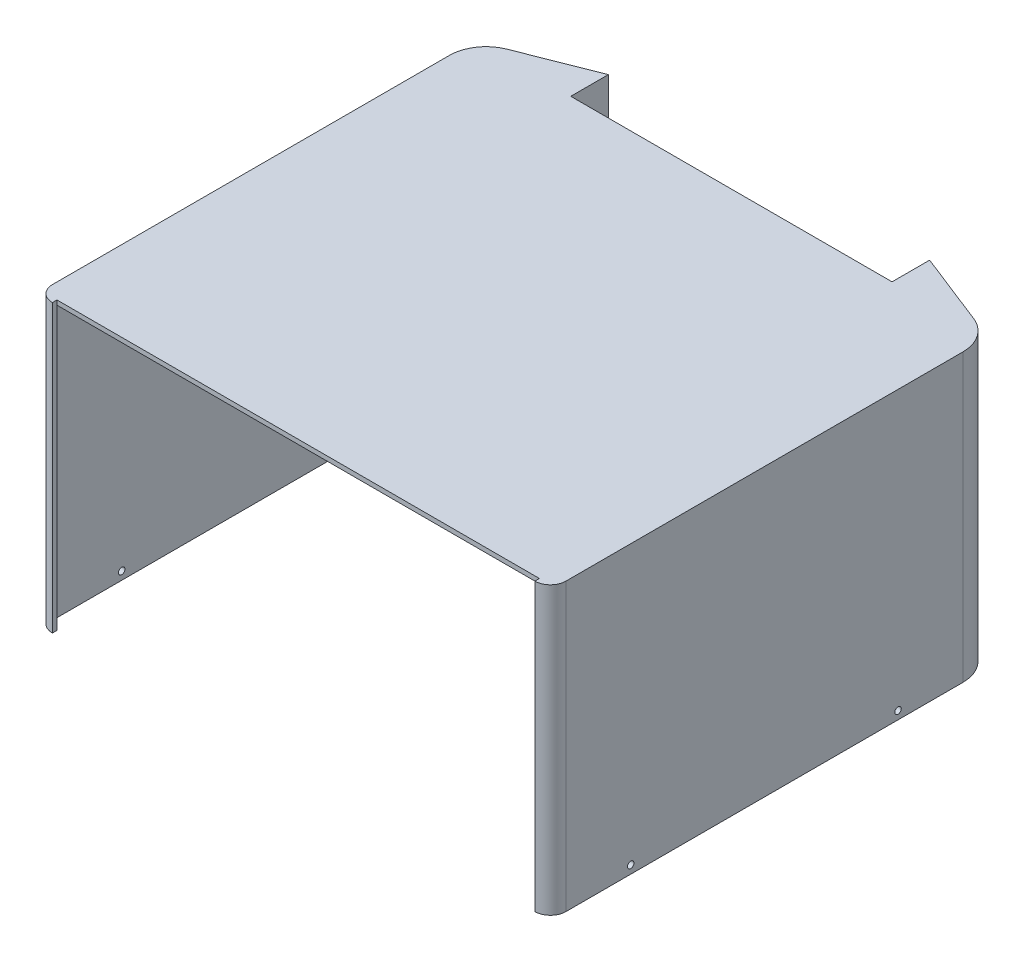
from build123d import *

# Parameters (mm, degrees)
BOSS_EXTRUDE2_DEPTH = 82
BOSS_EXTRUDE3_DEPTH = 1.5
SKETCH4_W           = 149
SKETCH4_H           = 82
CUT_EXTRUDE2_DEPTH  = 1.5
SKETCH5_W           = 99.231457505
SKETCH5_H           = 0.2
CUT_EXTRUDE3_DEPTH  = 18
SKETCH6_R           = 1
CUT_EXTRUDE4_DEPTH  = 243
CUT_EXTRUDE5_DEPTH  = 16.4
BOSS_EXTRUDE4_DEPTH = 5
BOSS_EXTRUDE6_DEPTH = 1.4
SKETCH10_W          = 99.231457505
SKETCH10_H          = 5.34
SKETCH10_H_2        = 1.4
BOSS_EXTRUDE7_DEPTH = 1.4


with BuildPart() as part:
    # Sketch1 → Boss-Extrude2 (new body)
    with BuildSketch(Plane(origin=(0, 0, 0), x_dir=(1, 0, 0), z_dir=(0, 1, 0))):
        with BuildLine():
            Line((-0.443676805, -72.739461341), (-0.443676805, -74.139461341))
            Line((-0.443676805, -74.139461341), (74.056323195, -74.139461341))
            ThreePointArc((74.056323195, -74.139461341), (77.450435745, -72.733573891), (78.856323195, -69.339461341))
            Line((78.856323195, -69.339461341), (78.856323195, -3.839461341))
            Line((78.856323195, -3.839461341), (78.856323195, 53.213038835))
            ThreePointArc((78.856323195, 53.213038835), (76.87852757, 59.630364191), (71.631399559, 63.820995158))
            Line((71.631399559, 63.820995158), (49.172051948, 72.660538659))
            Line((49.172051948, 72.660538659), (49.172051948, 71.156007577))
            Line((49.172051948, 71.156007577), (49.172051948, 59.660538659))
            Line((49.172051948, 59.660538659), (50.572051948, 59.660538659))
            Line((50.572051948, 59.660538659), (50.572051948, 70.604995984))
            Line((50.572051948, 70.604995984), (71.118670883, 62.51826368))
            ThreePointArc((71.118670883, 62.51826368), (75.721414752, 58.842271604), (77.456323195, 53.213038835))
            Line((77.456323195, 53.213038835), (77.456323195, -3.839461341))
            Line((77.456323195, -3.839461341), (77.456323195, -69.339461341))
            ThreePointArc((77.456323195, -69.339461341), (76.460486251, -71.743624398), (74.056323195, -72.739461341))
            Line((74.056323195, -72.739461341), (-0.443676805, -72.739461341))
        make_face()
        with BuildLine():
            Line((-74.943676805, -74.139461341), (-0.443676805, -74.139461341))
            Line((-0.443676805, -74.139461341), (-0.443676805, -72.739461341))
            Line((-0.443676805, -72.739461341), (-74.943676805, -72.739461341))
            ThreePointArc((-74.943676805, -72.739461341), (-77.347839861, -71.743624398), (-78.343676805, -69.339461341))
            Line((-78.343676805, -69.339461341), (-78.343676805, -3.839461341))
            Line((-78.343676805, -3.839461341), (-78.343676805, 53.213038835))
            ThreePointArc((-78.343676805, 53.213038835), (-76.608768361, 58.842271604), (-72.006024493, 62.51826368))
            Line((-72.006024493, 62.51826368), (-51.459405557, 70.604995984))
            Line((-51.459405557, 70.604995984), (-51.459405557, 59.660538659))
            Line((-51.459405557, 59.660538659), (-50.059405557, 59.660538659))
            Line((-50.059405557, 59.660538659), (-50.059405557, 71.156007577))
            Line((-50.059405557, 71.156007577), (-50.059405557, 72.660538659))
            Line((-50.059405557, 72.660538659), (-72.518753169, 63.820995158))
            ThreePointArc((-72.518753169, 63.820995158), (-77.765881179, 59.630364191), (-79.743676805, 53.213038835))
            Line((-79.743676805, 53.213038835), (-79.743676805, -3.839461341))
            Line((-79.743676805, -3.839461341), (-79.743676805, -69.339461341))
            ThreePointArc((-79.743676805, -69.339461341), (-78.337789355, -72.733573891), (-74.943676805, -74.139461341))
        make_face()
    extrude(amount=BOSS_EXTRUDE2_DEPTH)

    # Sketch3 → Boss-Extrude3 (add)
    with BuildSketch(Plane(origin=(0, 82, 0), x_dir=(1, 0, 0), z_dir=(0, 1, 0))):
        with BuildLine():
            Line((-50.059405557, 59.660538659), (49.172051948, 59.660538659))
            Line((49.172051948, 59.660538659), (50.572051948, 59.660538659))
            Line((50.572051948, 59.660538659), (50.572051948, 70.604995984))
            Line((50.572051948, 70.604995984), (71.118670883, 62.51826368))
            ThreePointArc((71.118670883, 62.51826368), (75.721414752, 58.842271604), (77.456323195, 53.213038835))
            Line((77.456323195, 53.213038835), (77.456323195, -69.339461341))
            ThreePointArc((77.456323195, -69.339461341), (76.460486251, -71.743624398), (74.056323195, -72.739461341))
            Line((74.056323195, -72.739461341), (-74.943676805, -72.739461341))
            ThreePointArc((-74.943676805, -72.739461341), (-77.347839861, -71.743624398), (-78.343676805, -69.339461341))
            Line((-78.343676805, -69.339461341), (-78.343676805, 53.213038835))
            ThreePointArc((-78.343676805, 53.213038835), (-76.608768361, 58.842271604), (-72.006024493, 62.51826368))
            Line((-72.006024493, 62.51826368), (-51.459405557, 70.604995984))
            Line((-51.459405557, 70.604995984), (-51.459405557, 59.660538659))
            Line((-51.459405557, 59.660538659), (-50.059405557, 59.660538659))
        make_face()
    extrude(amount=-BOSS_EXTRUDE3_DEPTH)

    # Sketch4 → Cut-Extrude2 (cut)
    with BuildSketch(Plane.XY.offset(74.139461341)):
        with Locations((-0.443676805, 41)):
            Rectangle(SKETCH4_W, SKETCH4_H)
    extrude(amount=-CUT_EXTRUDE2_DEPTH, mode=Mode.SUBTRACT)

    # Sketch5 → Cut-Extrude3 (cut)
    with BuildSketch(Plane(origin=(0, 82, 0), x_dir=(1, 0, 0), z_dir=(0, 1, 0))):
        with Locations((-0.443676805, 59.560538659)):
            Rectangle(SKETCH5_W, SKETCH5_H)
    extrude(amount=-CUT_EXTRUDE3_DEPTH, mode=Mode.SUBTRACT)

    # Sketch6 → Cut-Extrude4 (cut)
    with BuildSketch(Plane.ZY.offset(79.743676805)):
        with Locations((-33.213038835, 2.5)):
            Circle(SKETCH6_R)
        with Locations((49.339461341, 2.5)):
            Circle(SKETCH6_R)
    extrude(amount=-CUT_EXTRUDE4_DEPTH, mode=Mode.SUBTRACT)

    # Sketch7 → Cut-Extrude5 (cut)
    with BuildSketch(Plane.XZ.offset(-80.5)):
        with BuildLine():
            Line((-50.059405557, -59.460538659), (49.172051948, -59.460538659))
            Line((49.172051948, -59.460538659), (49.172051948, -59.660538659))
            Line((49.172051948, -59.660538659), (50.572051948, -59.660538659))
            Line((50.572051948, -59.660538659), (50.572051948, -70.604995984))
            Line((50.572051948, -70.604995984), (71.118670883, -62.51826368))
            ThreePointArc((71.118670883, -62.51826368), (75.721414752, -58.842271604), (77.456323195, -53.213038835))
            Line((77.456323195, -53.213038835), (77.456323195, 69.339461341))
            ThreePointArc((77.456323195, 69.339461341), (76.460486251, 71.743624398), (74.056323195, 72.739461341))
            Line((74.056323195, 72.739461341), (74.056323195, 72.639461341))
            Line((74.056323195, 72.639461341), (-74.943676805, 72.639461341))
            Line((-74.943676805, 72.639461341), (-74.943676805, 72.739461341))
            ThreePointArc((-74.943676805, 72.739461341), (-77.347839861, 71.743624398), (-78.343676805, 69.339461341))
            Line((-78.343676805, 69.339461341), (-78.343676805, -53.213038835))
            ThreePointArc((-78.343676805, -53.213038835), (-76.608768361, -58.842271604), (-72.006024493, -62.51826368))
            Line((-72.006024493, -62.51826368), (-51.459405557, -70.604995984))
            Line((-51.459405557, -70.604995984), (-51.459405557, -59.660538659))
            Line((-51.459405557, -59.660538659), (-50.059405557, -59.660538659))
            Line((-50.059405557, -59.660538659), (-50.059405557, -59.460538659))
        make_face()
    extrude(amount=-CUT_EXTRUDE5_DEPTH, mode=Mode.SUBTRACT)

    # Sketch8 → Boss-Extrude4 (add)
    with BuildSketch(Plane(origin=(0, 82, 0), x_dir=(1, 0, 0), z_dir=(0, 1, 0))):
        with BuildLine():
            Line((74.056323195, -72.739461341), (74.056323195, -74.139461341))
            ThreePointArc((74.056323195, -74.139461341), (77.450435745, -72.733573891), (78.856323195, -69.339461341))
            Line((78.856323195, -69.339461341), (78.856323195, 53.213038835))
            ThreePointArc((78.856323195, 53.213038835), (76.87852757, 59.630364191), (71.631399559, 63.820995158))
            Line((71.631399559, 63.820995158), (49.172051948, 72.660538659))
            Line((49.172051948, 72.660538659), (49.172051948, 59.660538659))
            Line((49.172051948, 59.660538659), (50.572051948, 59.660538659))
            Line((50.572051948, 59.660538659), (50.572051948, 70.604995984))
            Line((50.572051948, 70.604995984), (71.118670883, 62.51826368))
            ThreePointArc((71.118670883, 62.51826368), (75.721414752, 58.842271604), (77.456323195, 53.213038835))
            Line((77.456323195, 53.213038835), (77.456323195, -69.339461341))
            ThreePointArc((77.456323195, -69.339461341), (76.460486251, -71.743624398), (74.056323195, -72.739461341))
        make_face()
        with BuildLine():
            Line((-51.459405557, 59.660538659), (-50.059405557, 59.660538659))
            Line((-50.059405557, 59.660538659), (-50.059405557, 72.660538659))
            Line((-50.059405557, 72.660538659), (-72.518753169, 63.820995158))
            ThreePointArc((-72.518753169, 63.820995158), (-77.765881179, 59.630364191), (-79.743676805, 53.213038835))
            Line((-79.743676805, 53.213038835), (-79.743676805, -69.339461341))
            ThreePointArc((-79.743676805, -69.339461341), (-78.337789355, -72.733573891), (-74.943676805, -74.139461341))
            Line((-74.943676805, -74.139461341), (-74.943676805, -72.739461341))
            ThreePointArc((-74.943676805, -72.739461341), (-77.347839861, -71.743624398), (-78.343676805, -69.339461341))
            Line((-78.343676805, -69.339461341), (-78.343676805, 53.213038835))
            ThreePointArc((-78.343676805, 53.213038835), (-76.608768361, 58.842271604), (-72.006024493, 62.51826368))
            Line((-72.006024493, 62.51826368), (-51.459405557, 70.604995984))
            Line((-51.459405557, 70.604995984), (-51.459405557, 59.660538659))
        make_face()
    extrude(amount=BOSS_EXTRUDE4_DEPTH)

    # Sketch9 → Boss-Extrude6 (add)
    with BuildSketch(Plane(origin=(0, 87, 0), x_dir=(1, 0, 0), z_dir=(0, 1, 0))):
        with BuildLine():
            Line((77.456323195, 53.213038835), (77.456323195, -69.339461341))
            ThreePointArc((77.456323195, -69.339461341), (76.460486251, -71.743624398), (74.056323195, -72.739461341))
            Line((74.056323195, -72.739461341), (-74.943676805, -72.739461341))
            ThreePointArc((-74.943676805, -72.739461341), (-77.347839861, -71.743624398), (-78.343676805, -69.339461341))
            Line((-78.343676805, -69.339461341), (-78.343676805, 53.213038835))
            ThreePointArc((-78.343676805, 53.213038835), (-76.608768361, 58.842271604), (-72.006024493, 62.51826368))
            Line((-72.006024493, 62.51826368), (-51.459405557, 70.604995984))
            Line((-51.459405557, 70.604995984), (-51.459405557, 59.660538659))
            Line((-51.459405557, 59.660538659), (-50.059405557, 59.660538659))
            Line((-50.059405557, 59.660538659), (49.172051948, 59.660538659))
            Line((49.172051948, 59.660538659), (50.572051948, 59.660538659))
            Line((50.572051948, 59.660538659), (50.572051948, 70.604995984))
            Line((50.572051948, 70.604995984), (71.118670883, 62.51826368))
            ThreePointArc((71.118670883, 62.51826368), (75.721414752, 58.842271604), (77.456323195, 53.213038835))
        make_face()
        with BuildLine():
            Line((-72.006024493, 62.51826368), (-51.459405557, 70.604995984))
            Line((-51.459405557, 70.604995984), (-51.459405557, 59.660538659))
            Line((-51.459405557, 59.660538659), (-50.059405557, 59.660538659))
            Line((-50.059405557, 59.660538659), (-50.059405557, 72.660538659))
            Line((-50.059405557, 72.660538659), (-72.518753169, 63.820995158))
            ThreePointArc((-72.518753169, 63.820995158), (-77.765881179, 59.630364191), (-79.743676805, 53.213038835))
            Line((-79.743676805, 53.213038835), (-79.743676805, -69.339461341))
            ThreePointArc((-79.743676805, -69.339461341), (-78.337789355, -72.733573891), (-74.943676805, -74.139461341))
            Line((-74.943676805, -74.139461341), (-74.943676805, -72.739461341))
            ThreePointArc((-74.943676805, -72.739461341), (-77.347839861, -71.743624398), (-78.343676805, -69.339461341))
            Line((-78.343676805, -69.339461341), (-78.343676805, 53.213038835))
            ThreePointArc((-78.343676805, 53.213038835), (-76.608768361, 58.842271604), (-72.006024493, 62.51826368))
        make_face()
        with BuildLine():
            ThreePointArc((77.456323195, 53.213038835), (75.721414752, 58.842271604), (71.118670883, 62.51826368))
            Line((71.118670883, 62.51826368), (50.572051948, 70.604995984))
            Line((50.572051948, 70.604995984), (50.572051948, 59.660538659))
            Line((50.572051948, 59.660538659), (49.172051948, 59.660538659))
            Line((49.172051948, 59.660538659), (49.172051948, 72.660538659))
            Line((49.172051948, 72.660538659), (71.631399559, 63.820995158))
            ThreePointArc((71.631399559, 63.820995158), (76.87852757, 59.630364191), (78.856323195, 53.213038835))
            Line((78.856323195, 53.213038835), (78.856323195, -69.339461341))
            ThreePointArc((78.856323195, -69.339461341), (77.450435745, -72.733573891), (74.056323195, -74.139461341))
            Line((74.056323195, -74.139461341), (74.056323195, -72.739461341))
            ThreePointArc((74.056323195, -72.739461341), (76.460486251, -71.743624398), (77.456323195, -69.339461341))
            Line((77.456323195, -69.339461341), (77.456323195, 53.213038835))
        make_face()
    extrude(amount=BOSS_EXTRUDE6_DEPTH)

    # Sketch10 → Boss-Extrude7 (add)
    with BuildSketch(Plane(origin=(0, 0, -59.660538659), x_dir=(-1, 0, 0), z_dir=(0, 0, -1))):
        with Locations((0.443676805, 84.33)):
            Rectangle(SKETCH10_W, SKETCH10_H)
        with Locations((0.443676805, 87.7)):
            Rectangle(SKETCH10_W, SKETCH10_H_2)
    extrude(amount=BOSS_EXTRUDE7_DEPTH)


solid = part.part
